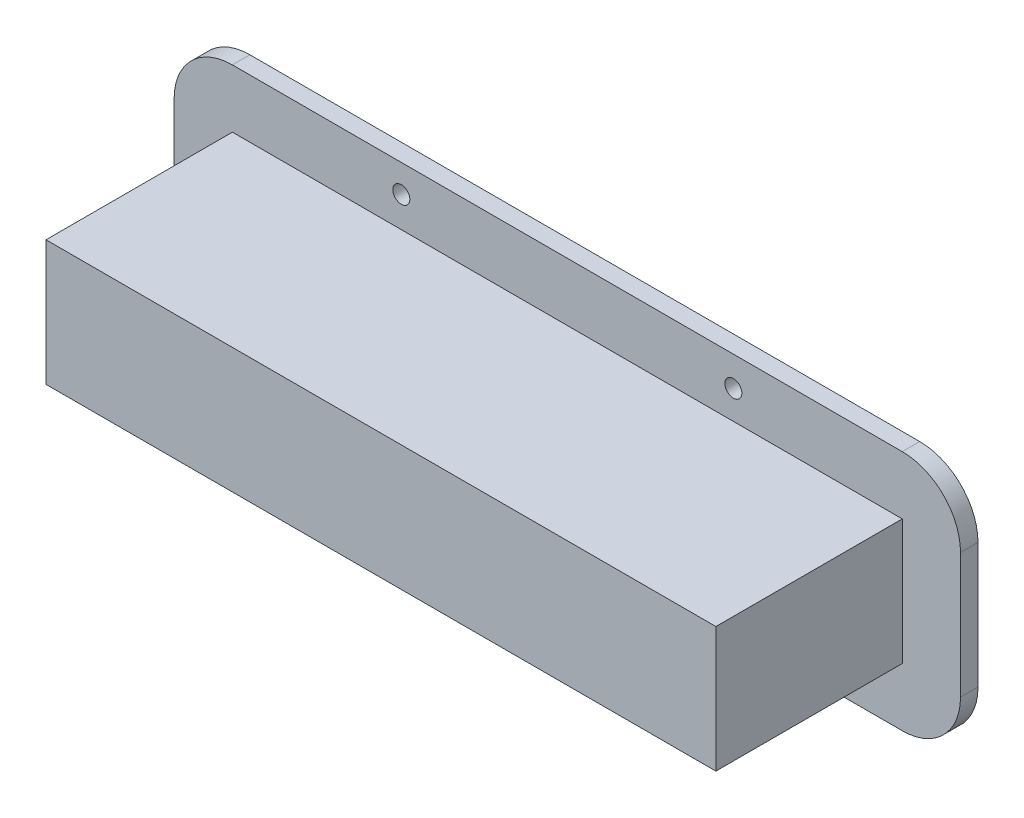
from build123d import *

# Parameters (mm, degrees)
SKETCH2_W           = 115
SKETCH2_H           = 21.5
BOSS_EXTRUDE1_DEPTH = 35
BOSS_EXTRUDE2_DEPTH = 3
SKETCH8_W           = 105
SKETCH8_H           = 11.5
CUT_EXTRUDE2_DEPTH  = 30
SKETCH9_R           = 1.46
CUT_EXTRUDE3_DEPTH  = 33
SKETCH10_W          = 15
SKETCH10_H          = 8.5
CUT_EXTRUDE4_DEPTH  = 88


with BuildPart() as part:
    # Sketch2 → Boss-Extrude1 (new body)
    with BuildSketch(Plane.XY):
        with Locations((9.785277127, -0.97863388)):
            Rectangle(SKETCH2_W, SKETCH2_H)
    extrude(amount=BOSS_EXTRUDE1_DEPTH)

    # Sketch7 → Boss-Extrude2 (add)
    with BuildSketch(Plane.XY):
        with BuildLine():
            Line((-47.714722873, 19.77136612), (67.285277127, 19.77136612))
            ThreePointArc((67.285277127, 19.77136612), (74.356344939, 16.842433932), (77.285277127, 9.77136612))
            Line((77.285277127, 9.77136612), (77.285277127, -11.72863388))
            ThreePointArc((77.285277127, -11.72863388), (74.356344939, -18.799701692), (67.285277127, -21.72863388))
            Line((67.285277127, -21.72863388), (-47.714722873, -21.72863388))
            ThreePointArc((-47.714722873, -21.72863388), (-54.785790685, -18.799701692), (-57.714722873, -11.72863388))
            Line((-57.714722873, -11.72863388), (-57.714722873, 9.77136612))
            ThreePointArc((-57.714722873, 9.77136612), (-54.785790685, 16.842433932), (-47.714722873, 19.77136612))
        make_face()
    extrude(amount=BOSS_EXTRUDE2_DEPTH)

    # Sketch8 → Cut-Extrude2 (cut)
    with BuildSketch(Plane.XY):
        with Locations((9.785277127, -0.97863388)):
            Rectangle(SKETCH8_W, SKETCH8_H)
    extrude(amount=CUT_EXTRUDE2_DEPTH, mode=Mode.SUBTRACT)

    # Sketch9 → Cut-Extrude3 (cut)
    with BuildSketch(Plane.XY):
        with Locations((38.285277127, 14.68536612)):
            Circle(SKETCH9_R)
        with Locations((-18.714722873, 15.00736612)):
            Circle(SKETCH9_R)
        with Locations((-18.714722873, -16.34263388)):
            Circle(SKETCH9_R)
        with Locations((38.285277127, -16.66463388)):
            Circle(SKETCH9_R)
    extrude(amount=CUT_EXTRUDE3_DEPTH, mode=Mode.SUBTRACT)

    # Sketch10 → Cut-Extrude4 (cut)
    with BuildSketch(Plane(origin=(0, 0, 0), x_dir=(0, 0, -1), z_dir=(1, 0, 0))):
        with Locations((-19, -0.97863388)):
            Rectangle(SKETCH10_W, SKETCH10_H)
    extrude(amount=-CUT_EXTRUDE4_DEPTH, mode=Mode.SUBTRACT)


solid = part.part
